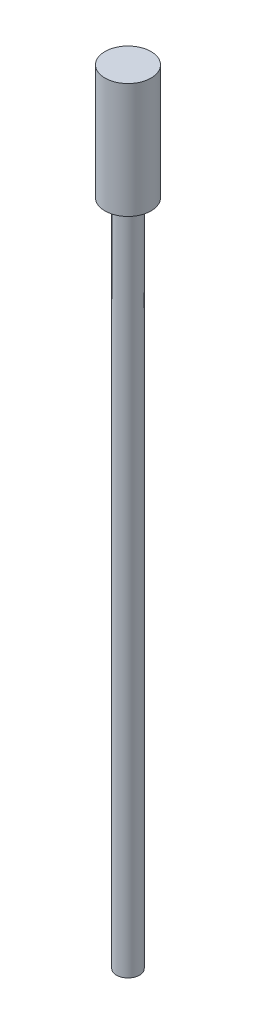
from build123d import *


with BuildPart() as part:
    # S2D0002 → Revolve1 (revolve)
    with BuildSketch(Plane.XY):
        Polygon((0.25, 0), (0.25, -14.5), (0, -14.5), (0, 2.5), (0.5, 2.5), (0.5, 0), align=None)
    revolve(axis=Axis((0, 3.35, 0), (0, -1, 0)))


solid = part.part
